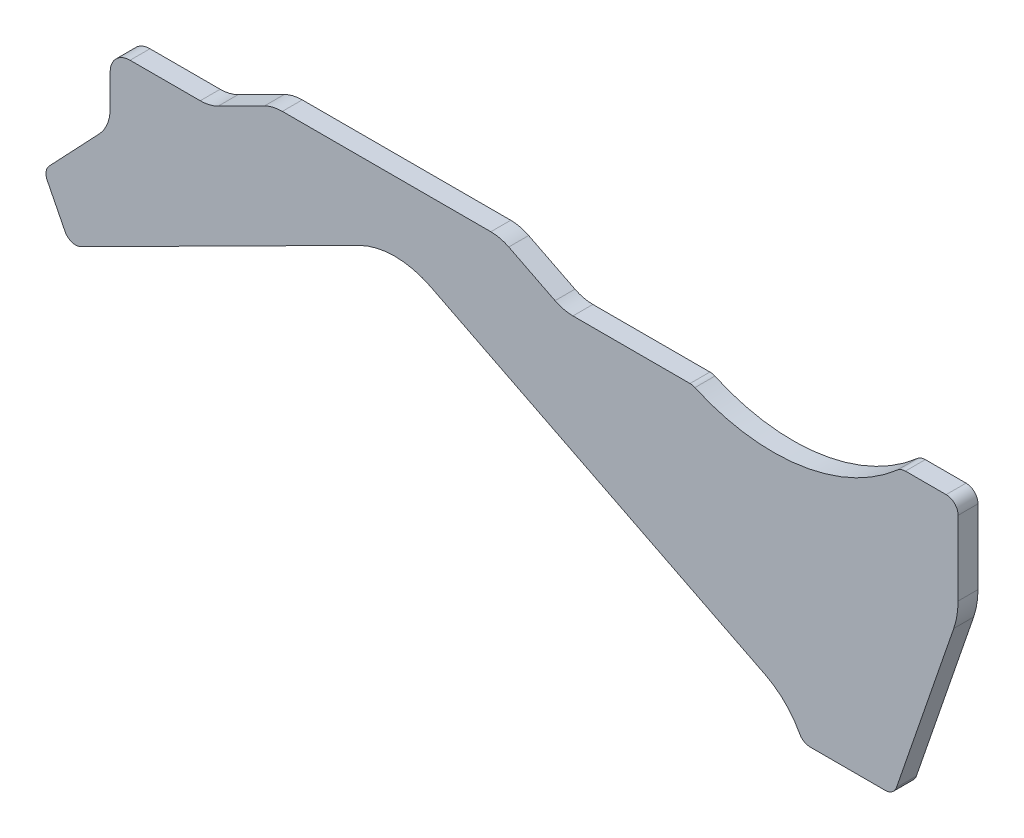
from build123d import *

# Parameters (mm, degrees)
EXTRUDE1_DEPTH = 5


with BuildPart() as part:
    # Sketch1 → Extrude1 (new body)
    with BuildSketch(Plane.XY):
        with BuildLine():
            Line((9.001968821, -4.537365816), (93.001968821, -46.87685134))
            ThreePointArc((93.001968821, -46.87685134), (98.008613867, -50.462021725), (101.687244374, -55.40040394))
            ThreePointArc((101.687244374, -55.40040394), (102.79133326, -56.569164438), (104.34033103, -57))
            Line((104.34033103, -57), (123.176722972, -57))
            ThreePointArc((123.176722972, -57), (124.918831839, -56.442346555), (126.013278698, -54.976704463))
            Line((126.013278698, -54.976704463), (140.410371512, -13.164510908))
            ThreePointArc((140.410371512, -13.164510908), (141.225712031, -9.954099936), (141.5, -6.653147818))
            Line((141.5, -6.653147818), (141.5, 12))
            ThreePointArc((141.5, 12), (140.621320344, 14.121320344), (138.5, 15))
            Line((138.5, 15), (128.260336739, 15))
            ThreePointArc((128.260336739, 15), (127.204940422, 14.808226952), (126.284475151, 14.257425743))
            ThreePointArc((126.284475151, 14.257425743), (101.948595314, 3.0109904), (75.399274569, 6.732673267))
            ThreePointArc((75.399274569, 6.732673267), (74.794571806, 6.932406844), (74.161334016, 7))
            Line((74.161334016, 7), (44.749434711, 7))
            ThreePointArc((44.749434711, 7), (42.436200432, 7.271230953), (40.2484503, 8.070210566))
            Line((40.2484503, 8.070210566), (28.623258855, 13.929789434))
            ThreePointArc((28.623258855, 13.929789434), (26.435508723, 14.728769047), (24.122274444, 15))
            Line((24.122274444, 15), (-28.250565289, 15))
            ThreePointArc((-28.250565289, 15), (-30.563799568, 14.728769047), (-32.7515497, 13.929789434))
            Line((-32.7515497, 13.929789434), (-44.376741145, 8.070210566))
            ThreePointArc((-44.376741145, 8.070210566), (-46.564491277, 7.271230953), (-48.877725556, 7))
            Line((-48.877725556, 7), (-66.5, 7))
            ThreePointArc((-66.5, 7), (-70.035533906, 5.535533906), (-71.5, 2))
            Line((-71.5, 2), (-71.5, -6.015697791))
            ThreePointArc((-71.5, -6.015697791), (-72.210213011, -9.717029673), (-74.23997154, -12.892614743))
            Line((-74.23997154, -12.892614743), (-86.801586013, -26.154033952))
            ThreePointArc((-86.801586013, -26.154033952), (-87.591784672, -27.781510557), (-87.302514305, -29.56740436))
            Line((-87.302514305, -29.56740436), (-82.850295323, -38.400444957))
            ThreePointArc((-82.850295323, -38.400444957), (-81.110849912, -39.899247013), (-78.82106317, -39.729086464))
            Line((-78.82106317, -39.729086464), (-9.001968821, -4.537365816))
            ThreePointArc((-9.001968821, -4.537365816), (0, -2.396944684), (9.001968821, -4.537365816))
        make_face()
    extrude(amount=EXTRUDE1_DEPTH)


solid = part.part
